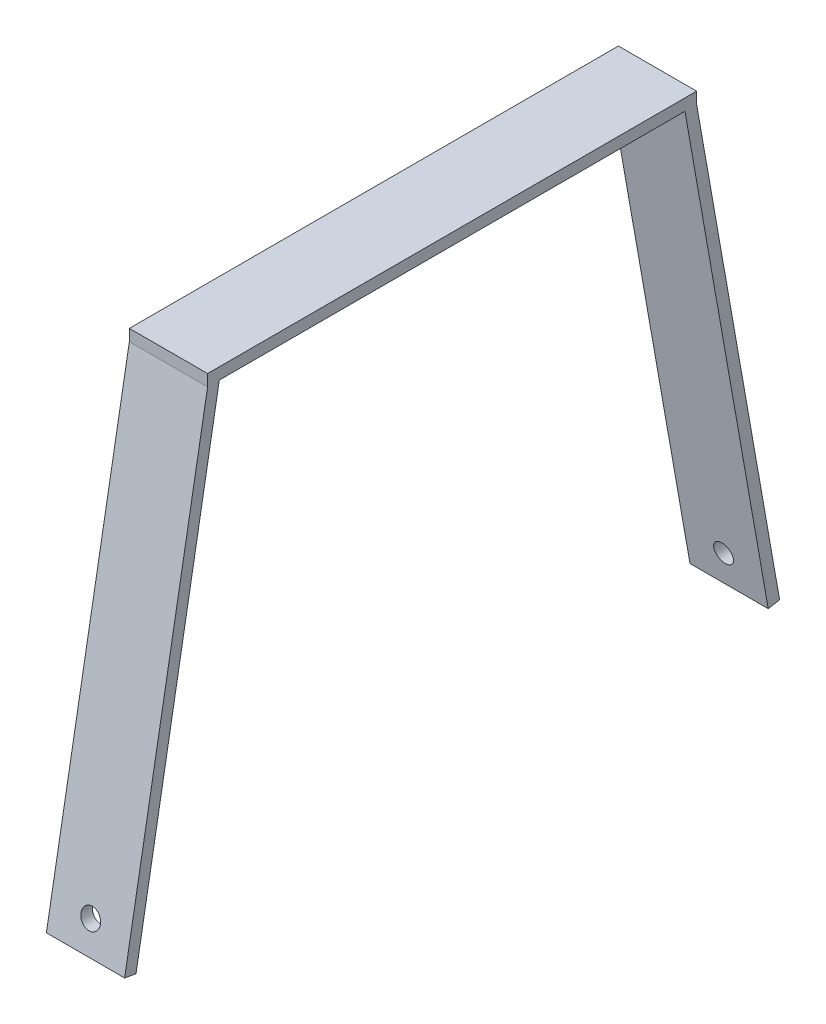
from build123d import *

# Parameters (mm, degrees)
SKETCH2_W           = 20.32
SKETCH2_H           = 127
BOSS_EXTRUDE1_DEPTH = 2.999994
BOSS_EXTRUDE2_DEPTH = 2.999994
SKETCH6_R           = 2.54
CUT_EXTRUDE2_DEPTH  = 171.130289375


with BuildPart() as part:
    # Sketch2 → Boss-Extrude1 (new body)
    with BuildSketch(Plane(origin=(0, 0, 0), x_dir=(1, 0, 0), z_dir=(0, 1, 0))):
        Rectangle(SKETCH2_W, SKETCH2_H)
    extrude(amount=BOSS_EXTRUDE1_DEPTH)

    # Sketch4 → Boss-Extrude2 (add)
    with BuildSketch(Plane(origin=(0, 10.859139551, 61.58524071), x_dir=(1, 0, 0), z_dir=(0, 0.173648178, 0.984807753))):
        Polygon((10.16, -8.072241932), (-10.16, -8.072241932), (-10.16, -135.072241932), (0, -135.072241932), (10.16, -135.072241932), align=None)
    boss_extrude2 = extrude(amount=-BOSS_EXTRUDE2_DEPTH)

    # Mirror1: Boss-Extrude2 across plane
    add(boss_extrude2.mirror(Plane.XY))

    # Sketch6 → Cut-Extrude2 (cut, through all)
    with BuildSketch(Plane.XY.offset(85.09)):
        with Locations((0, -114.54105152)):
            Circle(SKETCH6_R)
    extrude(amount=-CUT_EXTRUDE2_DEPTH, mode=Mode.SUBTRACT)


solid = part.part
